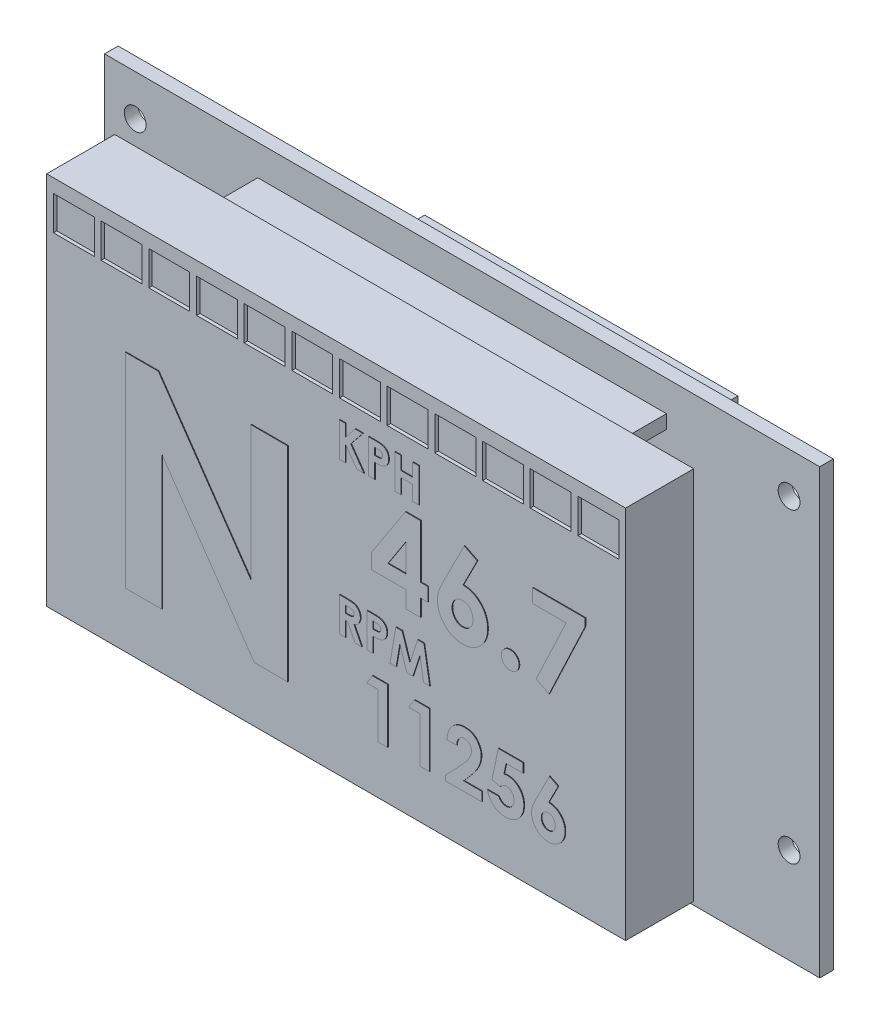
from build123d import *

# Parameters (mm, degrees)
SKETCH_1_W          = 105
SKETCH_1_H          = 67
EXTRUDE_1_DEPTH     = 2
SKETCH_2_R          = 1.6
CUT_EXTRUDE_1_DEPTH = 3
SKETCH_5_W          = 60
SKETCH_5_H          = 2
EXTRUDE_4_DEPTH     = 8.5
SKETCH_6_W          = 85
SKETCH_6_H          = 55
EXTRUDE_5_DEPTH     = 10
EXTRUDE_8_DEPTH     = 0.1
EXTRUDE_10_DEPTH    = 0.1
EXTRUDE_11_DEPTH    = 0.1
EXTRUDE_12_DEPTH    = 0.1
EXTRUDE_13_DEPTH    = 0.1
SKETCH_18_W         = 105
SKETCH_18_H         = 10
CUT_EXTRUDE_2_DEPTH = 10
SKETCH_19_W         = 45
SKETCH_19_H         = 2.5
EXTRUDE_14_DEPTH    = 8.5
SKETCH_22_W         = 46
SKETCH_22_H         = 19
EXTRUDE_15_DEPTH    = 7
SKETCH_28_W         = 105
SKETCH_28_H         = 8
EXTRUDE_16_DEPTH    = 2
SKETCH_29_W         = 6
SKETCH_29_H         = 5
CUT_EXTRUDE_3_DEPTH = 0.5


with BuildPart() as part:
    # ｽｹｯﾁ1 → ﾎﾞｽ - 押し出し1 (new body)
    with BuildSketch(Plane.XY):
        Rectangle(SKETCH_1_W, SKETCH_1_H)
    extrude(amount=EXTRUDE_1_DEPTH)

    # ｽｹｯﾁ2 → ｶｯﾄ - 押し出し1 (cut, through all)
    with BuildSketch(Plane.XY.offset(2)):
        with Locations((48, 17.5)):
            Circle(SKETCH_2_R)
        with Locations((48, -27.5)):
            Circle(SKETCH_2_R)
        with Locations((-48, -27.5)):
            Circle(SKETCH_2_R)
        with Locations((-48, 17.5)):
            Circle(SKETCH_2_R)
    extrude(amount=-CUT_EXTRUDE_1_DEPTH, mode=Mode.SUBTRACT)

    # ｽｹｯﾁ5 → ﾎﾞｽ - 押し出し4 (add)
    with BuildSketch(Plane.XY.offset(2)):
        with Locations((0, 18)):
            Rectangle(SKETCH_5_W, SKETCH_5_H)
        with Locations((0, -30)):
            Rectangle(SKETCH_5_W, SKETCH_5_H)
    extrude(amount=EXTRUDE_4_DEPTH)

    # ｽｹｯﾁ6 → ﾎﾞｽ - 押し出し5 (add)
    with BuildSketch(Plane.XY.offset(10.5)):
        with Locations((0, -5)):
            Rectangle(SKETCH_6_W, SKETCH_6_H)
    extrude(amount=EXTRUDE_5_DEPTH)

    # ｽｹｯﾁ10 → ﾎﾞｽ - 押し出し8 (add)
    with BuildSketch(Plane.XY.offset(20.5)):
        Polygon((-30.856693287, 5.696745875), (-26.006933671, 5.696745875), (-12.395154825, -14.044840664), (-12.395154825, 5.696745875), (-7.010539441, 5.696745875), (-7.010539441, -24.303254125), (-11.896356748, -24.303254125), (-25.472077902, -4.62176374), (-25.472077902, -24.303254125), (-30.856693287, -24.303254125), align=None)
    extrude(amount=EXTRUDE_8_DEPTH)

    # ｽｹｯﾁ12 → ﾎﾞｽ - 押し出し10 (add)
    with BuildSketch(Plane.XY.offset(20.5)):
        Polygon((0.576923077, 12.805093408), (1.474358974, 12.805093408), (1.474358974, 11.045277703), (2.892628205, 12.805093408), (4.025440705, 12.805093408), (2.243589744, 10.593554947), (4.198717949, 7.805093408), (3.117988782, 7.805093408), (1.474358974, 10.149845011), (1.474358974, 7.805093408), (0.576923077, 7.805093408), align=None)
        with BuildLine():
            Line((4.871794872, 12.805093408), (5.873397436, 12.805093408))
            add(Edge.make_bspline(
                [(5.873397436, 12.805093408), (5.938840848, 12.80480047), (6.065094908, 12.804235329), (6.24716365, 12.797382255), (6.415130978, 12.785101127), (6.568958304, 12.769923596), (6.708582377, 12.748645288), (6.834178047, 12.724251373), (6.94577138, 12.694532485), (7.044620756, 12.659256578), (7.133334878, 12.617667661), (7.21728705, 12.573372496), (7.294579944, 12.520507778), (7.369114766, 12.464771043), (7.436630232, 12.400837782), (7.50133836, 12.332962846), (7.560498585, 12.25845437), (7.614385033, 12.178214261), (7.663268345, 12.093725011), (7.705976076, 12.00483558), (7.740618196, 11.911405308), (7.769678627, 11.814038585), (7.793020249, 11.712739652), (7.808557175, 11.606885513), (7.819110637, 11.497215282), (7.820041834, 11.422573653), (7.820512821, 11.384820972)],
                knots=[0, 0, 0, 0, 0.000196324, 0.000378751, 0.00054645, 0.000701527, 0.000842329, 0.000970009, 0.001085176, 0.001188463, 0.001284371, 0.001378936, 0.001472831, 0.001564984, 0.001657831, 0.001751361, 0.001846154, 0.001942828, 0.002041098, 0.002138763, 0.00223829, 0.002339695, 0.002443447, 0.002549829, 0.002660459, 0.00277368, 0.00277368, 0.00277368, 0.00277368], degree=3))
            add(Edge.make_bspline(
                [(7.820512821, 11.384820972), (7.819831362, 11.34305608), (7.818492213, 11.260982936), (7.805364232, 11.140673775), (7.782937494, 11.025969882), (7.75362692, 10.91590394), (7.712755409, 10.812286777), (7.666061627, 10.712646055), (7.608613464, 10.619775395), (7.542969755, 10.532513096), (7.471279335, 10.450149675), (7.391840277, 10.37506322), (7.306166724, 10.306741869), (7.21475461, 10.244469609), (7.117260745, 10.188372057), (7.013755477, 10.137923918), (6.903532013, 10.094738682), (6.826775708, 10.072153153), (6.787860577, 10.060702383)],
                knots=[0, 0, 0, 0, 0.000125264, 0.00024616, 0.000362449, 0.000475684, 0.000587289, 0.000696151, 0.000805404, 0.000914178, 0.001023477, 0.001132583, 0.00124161, 0.0013519, 0.001464084, 0.001578762, 0.001697057, 0.00181871, 0.00181871, 0.00181871, 0.00181871], degree=3))
            add(Edge.make_bspline(
                [(6.787860577, 10.060702383), (6.762228833, 10.054325163), (6.706702221, 10.040510052), (6.61482093, 10.026484247), (6.508937389, 10.013588382), (6.388709207, 10.002505947), (6.25406707, 9.994972473), (6.105141347, 9.989089166), (5.941864548, 9.984811393), (5.828328318, 9.984659599), (5.769230769, 9.984580588)],
                knots=[0, 0, 0, 0, 7.9203e-05, 0.000171578, 0.000278544, 0.00039924, 0.000533694, 0.000683053, 0.000846364, 0.00102365, 0.00102365, 0.00102365, 0.00102365], degree=3))
            Line((5.769230769, 9.984580588), (5.769230769, 7.805093408))
            Line((5.769230769, 7.805093408), (4.871794872, 7.805093408))
            Line((4.871794872, 7.805093408), (4.871794872, 12.805093408))
        make_face()
        with BuildLine():
            Line((5.769230769, 10.882016485), (6.086738782, 10.882016485))
            add(Edge.make_bspline(
                [(6.086738782, 10.882016485), (6.144514378, 10.882382827), (6.250822332, 10.883056902), (6.396001457, 10.892804418), (6.512670194, 10.907690843), (6.604840663, 10.929041419), (6.677617979, 10.961443746), (6.740383857, 10.998927136), (6.794219753, 11.046323854), (6.840833715, 11.100482714), (6.878100173, 11.162713958), (6.90394252, 11.232004273), (6.920729201, 11.306897793), (6.922279607, 11.359018726), (6.923076923, 11.385822575)],
                knots=[0, 0, 0, 0, 0.000173303, 0.000318881, 0.000436167, 0.000526049, 0.000601409, 0.000674244, 0.000744535, 0.000815585, 0.000887902, 0.00096082, 0.001036651, 0.001116936, 0.001116936, 0.001116936, 0.001116936], degree=3))
            add(Edge.make_bspline(
                [(6.923076923, 11.385822575), (6.922287809, 11.409240749), (6.920756737, 11.454677636), (6.909509069, 11.520254335), (6.89158352, 11.581385346), (6.86561009, 11.637432237), (6.832032594, 11.688299775), (6.791094833, 11.733967922), (6.743322116, 11.775414699), (6.706438786, 11.797353112), (6.687700321, 11.808498857)],
                knots=[0, 0, 0, 0, 7.0227e-05, 0.000136256, 0.000198999, 0.000260839, 0.000320843, 0.000381148, 0.000444376, 0.000509672, 0.000509672, 0.000509672, 0.000509672], degree=3))
            add(Edge.make_bspline(
                [(6.687700321, 11.808498857), (6.671827758, 11.816526067), (6.638222292, 11.833521315), (6.580988924, 11.853279533), (6.514942491, 11.869947767), (6.439637106, 11.883782241), (6.355373184, 11.894519229), (6.262165757, 11.902730338), (6.159877664, 11.906032345), (6.088742415, 11.907100847), (6.051682692, 11.907657511)],
                knots=[0, 0, 0, 0, 5.3311e-05, 0.000112871, 0.000181134, 0.000257552, 0.000342405, 0.000435898, 0.00053814, 0.000649336, 0.000649336, 0.000649336, 0.000649336], degree=3))
            Line((6.051682692, 11.907657511), (5.769230769, 11.907657511))
            Line((5.769230769, 11.907657511), (5.769230769, 10.882016485))
        make_face(mode=Mode.SUBTRACT)
        Polygon((8.717948718, 12.805093408), (9.615384615, 12.805093408), (9.615384615, 10.882016485), (11.346153846, 10.882016485), (11.346153846, 12.805093408), (12.243589744, 12.805093408), (12.243589744, 7.805093408), (11.346153846, 7.805093408), (11.346153846, 9.984580588), (9.615384615, 9.984580588), (9.615384615, 7.805093408), (8.717948718, 7.805093408), align=None)
    extrude(amount=EXTRUDE_10_DEPTH)

    # ｽｹｯﾁ13 → ﾎﾞｽ - 押し出し11 (add)
    with BuildSketch(Plane.XY.offset(20.5)):
        Polygon((10.259436868, 5.95275545), (12.504629176, 5.95275545), (12.504629176, -1.893398396), (13.581552253, -1.893398396), (13.581552253, -3.893398396), (12.504629176, -3.893398396), (12.504629176, -6.354936858), (10.350783022, -6.354936858), (10.350783022, -3.893398396), (5.273859945, -3.893398396), (5.273859945, -1.713109934), align=None)
        Polygon((10.350783022, -1.893398396), (10.350783022, 2.190736219), (7.694533022, -1.893398396), align=None, mode=Mode.SUBTRACT)
        with BuildLine():
            Line((18.918090715, 5.95275545), (20.824340715, 4.986409296))
            Line((20.824340715, 4.986409296), (18.732994561, 0.875832373))
            add(Edge.make_bspline(
                [(18.732994561, 0.875832373), (18.856549329, 0.872633478), (19.099910708, 0.866332729), (19.457967596, 0.815409024), (19.800276646, 0.727374147), (20.130289346, 0.610684157), (20.443971602, 0.453968341), (20.746375442, 0.267546702), (21.029677525, 0.040185462), (21.300373727, -0.21171873), (21.546516393, -0.490792371), (21.760334814, -0.790665864), (21.946673794, -1.10404325), (22.091526217, -1.43793554), (22.208369006, -1.786808092), (22.29267622, -2.152055499), (22.340775844, -2.534735435), (22.347407179, -2.794707251), (22.350783022, -2.927052242)],
                knots=[0, 0, 0, 0, 0.000370575, 0.000729907, 0.001082052, 0.001429547, 0.001777865, 0.002132047, 0.002493208, 0.002865649, 0.003240356, 0.003607264, 0.003969248, 0.004331942, 0.004696821, 0.005071767, 0.005454605, 0.005851596, 0.005851596, 0.005851596, 0.005851596], degree=3))
            add(Edge.make_bspline(
                [(22.350783022, -2.927052242), (22.347619578, -3.054624786), (22.341366805, -3.306780999), (22.28967936, -3.677134346), (22.206149734, -4.032466724), (22.086769124, -4.372068491), (21.935026714, -4.697599628), (21.749456025, -5.008869112), (21.528518109, -5.303550928), (21.27792139, -5.580079278), (21.003975945, -5.832136913), (20.715222525, -6.056180409), (20.40921427, -6.241248837), (20.091735094, -6.397543463), (19.756940012, -6.514173112), (19.409839247, -6.602208293), (19.047800634, -6.653008414), (18.8020581, -6.659396587), (18.677706099, -6.662629165)],
                knots=[0, 0, 0, 0, 0.000382582, 0.0007562, 0.001119443, 0.001476, 0.001834116, 0.002195254, 0.00256112, 0.002937236, 0.003313198, 0.003676679, 0.004031644, 0.004384281, 0.004736303, 0.00509311, 0.005457203, 0.005830179, 0.005830179, 0.005830179, 0.005830179], degree=3))
            add(Edge.make_bspline(
                [(18.677706099, -6.662629165), (18.547671696, -6.659976359), (18.291976635, -6.654759976), (17.917830769, -6.596350228), (17.558992683, -6.508422495), (17.217479104, -6.382876631), (16.891166261, -6.223017787), (16.583895901, -6.025208546), (16.293079695, -5.791630215), (16.02181817, -5.527537936), (15.777431751, -5.238260978), (15.55945949, -4.937916181), (15.375054677, -4.626032237), (15.225783279, -4.30294261), (15.109318272, -3.969676838), (15.028282382, -3.625602412), (14.97548002, -3.271631987), (14.969290148, -3.031407626), (14.966167638, -2.910225319)],
                knots=[0, 0, 0, 0, 0.000389786, 0.000766462, 0.001133181, 0.001496695, 0.001855762, 0.002221178, 0.002590589, 0.002973073, 0.00335505, 0.003725312, 0.004085224, 0.004440147, 0.004791372, 0.005142367, 0.00549932, 0.00586269, 0.00586269, 0.00586269, 0.00586269], degree=3))
            add(Edge.make_bspline(
                [(14.966167638, -2.910225319), (14.967817511, -2.816383799), (14.971126441, -2.628178397), (15.004379209, -2.346351036), (15.054935096, -2.063783904), (15.113535989, -1.82534481), (15.173877268, -1.623719604), (15.234611228, -1.45308964), (15.309877591, -1.263727689), (15.395918192, -1.055150199), (15.495438697, -0.827608087), (15.607919226, -0.581721574), (15.733639807, -0.315628621), (15.823295897, -0.132863966), (15.870013792, -0.037629165)],
                knots=[0, 0, 0, 0, 0.000281414, 0.000564395, 0.00085014, 0.001142234, 0.001300414, 0.001481358, 0.001685359, 0.001911691, 0.002158212, 0.002430367, 0.002722847, 0.003041073, 0.003041073, 0.003041073, 0.003041073], degree=3))
            Line((15.870013792, -0.037629165), (18.918090715, 5.95275545))
        make_face()
        with BuildLine():
            add(Edge.make_bspline(
                [(18.629629176, -1.124167627), (18.526281082, -1.128907985), (18.324042429, -1.138184245), (18.036489308, -1.235329753), (17.774306104, -1.387726876), (17.54704246, -1.599969344), (17.356957333, -1.853607426), (17.217276113, -2.142915539), (17.133250095, -2.464032943), (17.12452033, -2.688552879), (17.120013792, -2.804456088)],
                knots=[0, 0, 0, 0, 0.000309042, 0.000604754, 0.000899948, 0.001213002, 0.001530792, 0.001845806, 0.002171143, 0.002518305, 0.002518305, 0.002518305, 0.002518305], degree=3))
            add(Edge.make_bspline(
                [(17.120013792, -2.804456088), (17.125349675, -2.920397893), (17.135728324, -3.145912454), (17.222913829, -3.47008747), (17.365663554, -3.765965434), (17.56586094, -4.022964772), (17.800889794, -4.23629412), (18.061508917, -4.394061374), (18.343371087, -4.490982975), (18.538342034, -4.502808696), (18.636840715, -4.508783011)],
                knots=[0, 0, 0, 0, 0.000347354, 0.000675626, 0.000999227, 0.001326653, 0.001646663, 0.001946374, 0.002235236, 0.002530165, 0.002530165, 0.002530165, 0.002530165], degree=3))
            add(Edge.make_bspline(
                [(18.636840715, -4.508783011), (18.740866454, -4.502702289), (18.944878998, -4.490776937), (19.239180471, -4.39793362), (19.508026633, -4.242809485), (19.745738644, -4.030163129), (19.949928744, -3.776096499), (20.091207669, -3.478480589), (20.182423799, -3.151965793), (20.191990714, -2.922889805), (20.196936868, -2.804456088)],
                knots=[0, 0, 0, 0, 0.000311667, 0.000611233, 0.000915953, 0.001236161, 0.001563164, 0.001886765, 0.002217981, 0.002572522, 0.002572522, 0.002572522, 0.002572522], degree=3))
            add(Edge.make_bspline(
                [(20.196936868, -2.804456088), (20.191302295, -2.688620554), (20.180390284, -2.464291516), (20.098428156, -2.14166975), (19.952090312, -1.853476738), (19.757704355, -1.598922365), (19.522619503, -1.386774538), (19.249943192, -1.234127901), (18.949254166, -1.138356356), (18.737724224, -1.128966161), (18.629629176, -1.124167627)],
                knots=[0, 0, 0, 0, 0.000347354, 0.000672691, 0.000989826, 0.001310512, 0.001628919, 0.001932452, 0.002241914, 0.002565318, 0.002565318, 0.002565318, 0.002565318], degree=3))
        make_face(mode=Mode.SUBTRACT)
        with BuildLine():
            add(Edge.make_bspline(
                [(25.65847533, -3.893398396), (25.745423546, -3.898165558), (25.916609565, -3.907551276), (26.163950022, -3.977595909), (26.38717621, -4.103441071), (26.586770247, -4.267584273), (26.75554194, -4.465070461), (26.877526302, -4.690279312), (26.953489024, -4.936666733), (26.961875362, -5.108391325), (26.966167638, -5.196283011)],
                knots=[0, 0, 0, 0, 0.000260726, 0.000513324, 0.000762919, 0.001024232, 0.001285235, 0.001536939, 0.001787908, 0.002051028, 0.002051028, 0.002051028, 0.002051028], degree=3))
            add(Edge.make_bspline(
                [(26.966167638, -5.196283011), (26.96190348, -5.284188814), (26.953572081, -5.455940985), (26.877000647, -5.70280851), (26.755724223, -5.929868372), (26.586756706, -6.129470754), (26.388002798, -6.296707389), (26.163436786, -6.421392075), (25.917080744, -6.495410161), (25.745506478, -6.504282508), (25.65847533, -6.508783011)],
                knots=[0, 0, 0, 0, 0.00026312, 0.000514089, 0.000767908, 0.001030753, 0.001293598, 0.001543193, 0.001796465, 0.002057191, 0.002057191, 0.002057191, 0.002057191], degree=3))
            add(Edge.make_bspline(
                [(25.65847533, -6.508783011), (25.57142356, -6.504319105), (25.39980864, -6.495518905), (25.153069654, -6.420768175), (24.926845722, -6.297539832), (24.728041876, -6.129267897), (24.558319487, -5.930575181), (24.440491064, -5.702092095), (24.363206389, -5.456034057), (24.354988886, -5.284220323), (24.350783022, -5.196283011)],
                knots=[0, 0, 0, 0, 0.000260726, 0.000513998, 0.000765703, 0.001028548, 0.001291393, 0.001544083, 0.001795051, 0.002058171, 0.002058171, 0.002058171, 0.002058171], degree=3))
            add(Edge.make_bspline(
                [(24.350783022, -5.196283011), (24.355016634, -5.108359267), (24.363288351, -4.936572041), (24.439966907, -4.691003979), (24.558508329, -4.464359811), (24.728027722, -4.267787552), (24.927676568, -4.102615126), (25.152553538, -3.97821126), (25.400279581, -3.907441729), (25.571506395, -3.898128659), (25.65847533, -3.893398396)],
                knots=[0, 0, 0, 0, 0.00026312, 0.000514089, 0.000764654, 0.001025657, 0.00128697, 0.001538674, 0.001791272, 0.002051998, 0.002051998, 0.002051998, 0.002051998], degree=3))
        make_face()
        Polygon((28.966167638, 5.645063142), (36.65847533, 5.645063142), (36.65847533, 4.527274681), (31.365206099, -6.662629165), (29.456552253, -5.701090704), (33.879629176, 3.645063142), (28.966167638, 3.645063142), align=None)
    extrude(amount=EXTRUDE_11_DEPTH)

    # ｽｹｯﾁ14 → ﾎﾞｽ - 押し出し12 (add)
    with BuildSketch(Plane.XY.offset(20.5)):
        with BuildLine():
            Line((0.576923077, -9.415261778), (1.622596154, -9.415261778))
            add(Edge.make_bspline(
                [(1.622596154, -9.415261778), (1.691714826, -9.41550711), (1.824649502, -9.415978951), (2.016334044, -9.423423365), (2.192422657, -9.433782878), (2.353176056, -9.44959177), (2.498525468, -9.470552449), (2.628616566, -9.495261622), (2.74344555, -9.523423021), (2.843980841, -9.558514347), (2.934708971, -9.598096831), (3.019280201, -9.64357783), (3.099560299, -9.6944509), (3.175012679, -9.752054648), (3.246293041, -9.815352798), (3.313535858, -9.884409065), (3.375790927, -9.959809018), (3.432672764, -10.041076225), (3.484515979, -10.126567463), (3.530334507, -10.216400113), (3.567594211, -10.310636646), (3.600517153, -10.407915142), (3.624230482, -10.509626215), (3.640722755, -10.614779691), (3.652797752, -10.723745721), (3.653492007, -10.797772404), (3.653846154, -10.835534214)],
                knots=[0, 0, 0, 0, 0.000207341, 0.000398776, 0.000575402, 0.000736458, 0.000883205, 0.001015799, 0.001133619, 0.001237515, 0.001334841, 0.001430288, 0.001525314, 0.001619667, 0.00171474, 0.001811071, 0.001908535, 0.00200774, 0.002108399, 0.002208289, 0.002309842, 0.002412147, 0.002516126, 0.002622664, 0.002731397, 0.002844618, 0.002844618, 0.002844618, 0.002844618], degree=3))
            add(Edge.make_bspline(
                [(3.653846154, -10.835534214), (3.652926208, -10.874948869), (3.651122362, -10.952233824), (3.641405864, -11.06575912), (3.623647158, -11.174372182), (3.596749014, -11.277755005), (3.565833092, -11.377194308), (3.524722845, -11.470855375), (3.478325869, -11.560100369), (3.423221536, -11.643666887), (3.362747222, -11.723411108), (3.292416868, -11.796277734), (3.216786799, -11.866183072), (3.131605574, -11.928748488), (3.040628061, -11.988204428), (2.942046631, -12.042087345), (2.836504663, -12.091751729), (2.762303432, -12.11944802), (2.724358974, -12.133611137)],
                knots=[0, 0, 0, 0, 0.000118257, 0.00023188, 0.000341546, 0.000447947, 0.000552157, 0.000653556, 0.000754365, 0.000853544, 0.000953514, 0.001054124, 0.001156939, 0.001262107, 0.001370733, 0.001482805, 0.001598862, 0.00172032, 0.00172032, 0.00172032, 0.00172032], degree=3))
            Line((2.724358974, -12.133611137), (3.878205128, -14.415261778))
            Line((3.878205128, -14.415261778), (2.880608974, -14.415261778))
            Line((2.880608974, -14.415261778), (1.778846154, -12.235774599))
            Line((1.778846154, -12.235774599), (1.474358974, -12.235774599))
            Line((1.474358974, -12.235774599), (1.474358974, -14.415261778))
            Line((1.474358974, -14.415261778), (0.576923077, -14.415261778))
            Line((0.576923077, -14.415261778), (0.576923077, -9.415261778))
        make_face()
        with BuildLine():
            Line((1.474358974, -11.338338701), (1.823918269, -11.338338701))
            add(Edge.make_bspline(
                [(1.823918269, -11.338338701), (1.866654799, -11.337857374), (1.94848607, -11.336935735), (2.066170185, -11.332660792), (2.173055429, -11.322360293), (2.269600801, -11.309345997), (2.356292109, -11.294319112), (2.432356098, -11.272784675), (2.498964797, -11.24970998), (2.555328891, -11.22103412), (2.603485078, -11.188423448), (2.645064864, -11.151376913), (2.679457308, -11.108500267), (2.707764044, -11.060958711), (2.729783607, -11.008331751), (2.745856201, -10.951197114), (2.754838404, -10.888903961), (2.755871837, -10.845913204), (2.756410256, -10.823514983)],
                knots=[0, 0, 0, 0, 0.000128221, 0.000245515, 0.000353154, 0.000450185, 0.000537801, 0.000616775, 0.000687116, 0.000748932, 0.000805883, 0.000861198, 0.000915322, 0.000970118, 0.001026671, 0.001085968, 0.001147728, 0.001214902, 0.001214902, 0.001214902, 0.001214902], degree=3))
            add(Edge.make_bspline(
                [(2.756410256, -10.823514983), (2.755392325, -10.797016253), (2.753392787, -10.744964408), (2.733551162, -10.670028003), (2.701967581, -10.600669233), (2.658675143, -10.537201478), (2.604153944, -10.481561263), (2.541586567, -10.43251397), (2.469622657, -10.393731041), (2.402989491, -10.368150234), (2.342368886, -10.352844973), (2.287660702, -10.341439628), (2.224308295, -10.333356333), (2.152263839, -10.324782559), (2.071710976, -10.319222901), (1.982210645, -10.315165459), (1.884019891, -10.31350536), (1.81557161, -10.312974655), (1.779847756, -10.312697675)],
                knots=[0, 0, 0, 0, 7.9354e-05, 0.000155877, 0.00023073, 0.000307128, 0.000385047, 0.000463582, 0.000544718, 0.000629358, 0.000676973, 0.000732171, 0.000796904, 0.000868468, 0.00094982, 0.001039053, 0.00113723, 0.001244406, 0.001244406, 0.001244406, 0.001244406], degree=3))
            Line((1.779847756, -10.312697675), (1.474358974, -10.312697675))
            Line((1.474358974, -10.312697675), (1.474358974, -11.338338701))
        make_face(mode=Mode.SUBTRACT)
        with BuildLine():
            Line((4.615384615, -9.415261778), (5.616987179, -9.415261778))
            add(Edge.make_bspline(
                [(5.616987179, -9.415261778), (5.682430592, -9.415554717), (5.808684652, -9.416119857), (5.990753393, -9.422972931), (6.158720722, -9.435254059), (6.312548048, -9.45043159), (6.45217212, -9.471709899), (6.577767791, -9.496103813), (6.689361124, -9.525822701), (6.7882105, -9.561098608), (6.876924621, -9.602687525), (6.960876794, -9.646982691), (7.038169688, -9.699847408), (7.11270451, -9.755584143), (7.180219976, -9.819517404), (7.244928104, -9.88739234), (7.304088329, -9.961900816), (7.357974777, -10.042140926), (7.406858088, -10.126630175), (7.44956582, -10.215519607), (7.48420794, -10.308949878), (7.513268371, -10.406316602), (7.536609992, -10.507615534), (7.552146918, -10.613469673), (7.56270038, -10.723139904), (7.563631578, -10.797781533), (7.564102564, -10.835534214)],
                knots=[0, 0, 0, 0, 0.000196324, 0.000378751, 0.00054645, 0.000701527, 0.000842329, 0.000970009, 0.001085176, 0.001188463, 0.001284371, 0.001378936, 0.001472831, 0.001564984, 0.001657831, 0.001751361, 0.001846154, 0.001942828, 0.002041098, 0.002138763, 0.00223829, 0.002339695, 0.002443447, 0.002549829, 0.002660459, 0.00277368, 0.00277368, 0.00277368, 0.00277368], degree=3))
            add(Edge.make_bspline(
                [(7.564102564, -10.835534214), (7.563421106, -10.877299106), (7.562081956, -10.95937225), (7.548953976, -11.079681411), (7.526527237, -11.194385304), (7.497216663, -11.304451246), (7.456345153, -11.408068409), (7.409651371, -11.507709131), (7.352203208, -11.600579791), (7.286559498, -11.68784209), (7.214869078, -11.770205511), (7.13543002, -11.845291966), (7.049756468, -11.913613317), (6.958344353, -11.975885577), (6.860850489, -12.031983129), (6.75734522, -12.082431268), (6.647121756, -12.125616504), (6.570365452, -12.148202033), (6.531450321, -12.159652804)],
                knots=[0, 0, 0, 0, 0.000125264, 0.00024616, 0.000362449, 0.000475684, 0.000587289, 0.000696151, 0.000805404, 0.000914178, 0.001023477, 0.001132583, 0.00124161, 0.0013519, 0.001464084, 0.001578762, 0.001697057, 0.00181871, 0.00181871, 0.00181871, 0.00181871], degree=3))
            add(Edge.make_bspline(
                [(6.531450321, -12.159652804), (6.505818576, -12.166030023), (6.450291965, -12.179845134), (6.358410673, -12.193870939), (6.252527132, -12.206766804), (6.132298951, -12.217849239), (5.997656814, -12.225382713), (5.848731091, -12.231266021), (5.685454291, -12.235543793), (5.571918061, -12.235695587), (5.512820513, -12.235774599)],
                knots=[0, 0, 0, 0, 7.9203e-05, 0.000171578, 0.000278544, 0.00039924, 0.000533694, 0.000683053, 0.000846364, 0.00102365, 0.00102365, 0.00102365, 0.00102365], degree=3))
            Line((5.512820513, -12.235774599), (5.512820513, -14.415261778))
            Line((5.512820513, -14.415261778), (4.615384615, -14.415261778))
            Line((4.615384615, -14.415261778), (4.615384615, -9.415261778))
        make_face()
        with BuildLine():
            Line((5.512820513, -11.338338701), (5.830328526, -11.338338701))
            add(Edge.make_bspline(
                [(5.830328526, -11.338338701), (5.888104121, -11.337972359), (5.994412076, -11.337298284), (6.1395912, -11.327550769), (6.256259938, -11.312664343), (6.348430407, -11.291313767), (6.421207722, -11.258911441), (6.4839736, -11.22142805), (6.537809496, -11.174031332), (6.584423459, -11.119872472), (6.621689916, -11.057641228), (6.647532264, -10.988350913), (6.664318945, -10.913457393), (6.665869351, -10.86133646), (6.666666667, -10.834532611)],
                knots=[0, 0, 0, 0, 0.000173303, 0.000318881, 0.000436167, 0.000526049, 0.000601409, 0.000674244, 0.000744535, 0.000815585, 0.000887902, 0.00096082, 0.001036651, 0.001116936, 0.001116936, 0.001116936, 0.001116936], degree=3))
            add(Edge.make_bspline(
                [(6.666666667, -10.834532611), (6.665877552, -10.811114438), (6.664346481, -10.76567755), (6.653098812, -10.700100852), (6.635173264, -10.63896984), (6.609199833, -10.58292295), (6.575622338, -10.532055411), (6.534684576, -10.486387264), (6.48691186, -10.444940487), (6.45002853, -10.423002074), (6.431290064, -10.411856329)],
                knots=[0, 0, 0, 0, 7.0227e-05, 0.000136256, 0.000198999, 0.000260839, 0.000320843, 0.000381148, 0.000444376, 0.000509672, 0.000509672, 0.000509672, 0.000509672], degree=3))
            add(Edge.make_bspline(
                [(6.431290064, -10.411856329), (6.415417502, -10.403829119), (6.381812035, -10.386833871), (6.324578667, -10.367075653), (6.258532235, -10.350407419), (6.18322685, -10.336572946), (6.098962927, -10.325835958), (6.005755501, -10.317624848), (5.903467407, -10.314322841), (5.832332159, -10.313254339), (5.795272436, -10.312697675)],
                knots=[0, 0, 0, 0, 5.3311e-05, 0.000112871, 0.000181134, 0.000257552, 0.000342405, 0.000435898, 0.00053814, 0.000649336, 0.000649336, 0.000649336, 0.000649336], degree=3))
            Line((5.795272436, -10.312697675), (5.512820513, -10.312697675))
            Line((5.512820513, -10.312697675), (5.512820513, -11.338338701))
        make_face(mode=Mode.SUBTRACT)
        Polygon((8.857171474, -9.415261778), (9.788661859, -9.415261778), (10.929487179, -12.902841906), (12.078325321, -9.415261778), (13.000801282, -9.415261778), (13.846153846, -14.415261778), (12.937700321, -14.415261778), (12.403846154, -11.257208893), (11.364182692, -14.415261778), (10.488782051, -14.415261778), (9.455128205, -11.257208893), (8.922275641, -14.415261778), (8.012820513, -14.415261778), align=None)
    extrude(amount=EXTRUDE_12_DEPTH)

    # ｽｹｯﾁ15 → ﾎﾞｽ - 押し出し13 (add)
    with BuildSketch(Plane.XY.offset(20.5)):
        Polygon((5.439536639, -17.307592752), (7.659087921, -17.307592752), (7.659087921, -25.307592752), (6.223190485, -25.307592752), (6.223190485, -18.640926085), (4.582164844, -18.640926085), align=None)
        Polygon((11.593382793, -17.307592752), (13.812934075, -17.307592752), (13.812934075, -25.307592752), (12.377036639, -25.307592752), (12.377036639, -18.640926085), (10.736010998, -18.640926085), align=None)
        with BuildLine():
            Line((17.812934075, -19.974259418), (16.377036639, -19.974259418))
            add(Edge.make_bspline(
                [(16.377036639, -19.974259418), (16.38323806, -19.865641374), (16.395355264, -19.653408236), (16.443554438, -19.345132808), (16.508139678, -19.053846428), (16.594337254, -18.780568047), (16.702650149, -18.525396966), (16.830291192, -18.287463293), (16.980521323, -18.068019754), (17.150143149, -17.868124629), (17.33627696, -17.688796868), (17.535058433, -17.52979361), (17.749528201, -17.398588122), (17.975767724, -17.290618153), (18.213738479, -17.204355165), (18.465692043, -17.146681377), (18.729446865, -17.107624122), (18.910008399, -17.104206456), (19.002036639, -17.102464547)],
                knots=[0, 0, 0, 0, 0.000326207, 0.00063739, 0.000934802, 0.001220652, 0.001495683, 0.001765295, 0.002029329, 0.002291978, 0.002550384, 0.00280367, 0.003054066, 0.003302794, 0.003554723, 0.003811658, 0.004077051, 0.00435292, 0.00435292, 0.00435292, 0.00435292], degree=3))
            add(Edge.make_bspline(
                [(19.002036639, -17.102464547), (19.114999998, -17.105989301), (19.335530947, -17.112870448), (19.655979909, -17.171568916), (19.955244202, -17.269751173), (20.23310629, -17.40693768), (20.487200684, -17.581218757), (20.717485248, -17.789020417), (20.91699581, -18.03470245), (21.086997325, -18.308042426), (21.228248266, -18.597470991), (21.327231042, -18.89675213), (21.392291355, -19.197944134), (21.399230441, -19.400751585), (21.402677664, -19.501503008)],
                knots=[0, 0, 0, 0, 0.000338687, 0.000661197, 0.000973372, 0.001280835, 0.001587541, 0.001894987, 0.002208111, 0.002533585, 0.002859001, 0.003171681, 0.003477486, 0.003779381, 0.003779381, 0.003779381, 0.003779381], degree=3))
            add(Edge.make_bspline(
                [(21.402677664, -19.501503008), (21.401335498, -19.56244459), (21.398634047, -19.68510494), (21.379850502, -19.870720156), (21.351671474, -20.059790954), (21.309184366, -20.252155224), (21.25619946, -20.447866888), (21.19192111, -20.647511646), (21.114858316, -20.849957583), (21.026297102, -21.057483195), (20.920643348, -21.270762235), (20.797624238, -21.49299184), (20.653974566, -21.723974874), (20.491429438, -21.965015543), (20.309199411, -22.215733689), (20.1063949, -22.47537407), (19.885351735, -22.744851575), (19.728471182, -22.924982165), (19.647869972, -23.017528649)],
                knots=[0, 0, 0, 0, 0.000182805, 0.000367941, 0.000559231, 0.000756001, 0.00095854, 0.001167341, 0.001384918, 0.001608181, 0.001843976, 0.002098627, 0.002369916, 0.002659714, 0.002970649, 0.003299545, 0.003647962, 0.00401612, 0.00401612, 0.00401612, 0.00401612], degree=3))
            Line((19.647869972, -23.017528649), (18.812934075, -23.974259418))
            Line((18.812934075, -23.974259418), (21.505241767, -23.974259418))
            Line((21.505241767, -23.974259418), (21.505241767, -25.307592752))
            Line((21.505241767, -25.307592752), (16.171908434, -25.307592752))
            Line((16.171908434, -25.307592752), (16.171908434, -24.580028649))
            Line((16.171908434, -24.580028649), (18.540498177, -22.059195316))
            add(Edge.make_bspline(
                [(18.540498177, -22.059195316), (18.609074937, -21.985661825), (18.741887784, -21.843249259), (18.930866778, -21.634101256), (19.101876075, -21.435624793), (19.251369656, -21.245706496), (19.387192754, -21.070506543), (19.503289026, -20.904744188), (19.600720663, -20.749917982), (19.706496524, -20.563224618), (19.80694882, -20.340559559), (19.899119882, -20.084040282), (19.955304523, -19.83886693), (19.96305978, -19.679106704), (19.966780229, -19.602464547)],
                knots=[0, 0, 0, 0, 0.00030164, 0.000584187, 0.000845616, 0.001087386, 0.001309189, 0.001510583, 0.001694215, 0.00185781, 0.002153973, 0.002425634, 0.002674899, 0.002904742, 0.002904742, 0.002904742, 0.002904742], degree=3))
            add(Edge.make_bspline(
                [(19.966780229, -19.602464547), (19.963998539, -19.528319172), (19.95860857, -19.384650621), (19.89937718, -19.180282872), (19.807613856, -18.995248737), (19.678306372, -18.835077246), (19.521674511, -18.70345371), (19.340671682, -18.605555823), (19.136773591, -18.54906919), (18.993837144, -18.541999082), (18.92030587, -18.538361982)],
                knots=[0, 0, 0, 0, 0.000221855, 0.00042988, 0.000632704, 0.000837933, 0.00104271, 0.001242748, 0.001450773, 0.001671165, 0.001671165, 0.001671165, 0.001671165], degree=3))
            add(Edge.make_bspline(
                [(18.92030587, -18.538361982), (18.882318677, -18.539705571), (18.807534787, -18.54235064), (18.697608314, -18.559958148), (18.593005377, -18.590989544), (18.492561688, -18.632567247), (18.397349207, -18.687678791), (18.307608092, -18.755612549), (18.222392805, -18.834642171), (18.142094179, -18.92452054), (18.069011947, -19.024824827), (18.004100575, -19.134638956), (17.950429677, -19.253894764), (17.903175868, -19.38101789), (17.866731469, -19.517373741), (17.840195425, -19.662146243), (17.820021843, -19.815099869), (17.815339644, -19.920241104), (17.812934075, -19.974259418)],
                knots=[0, 0, 0, 0, 0.000113962, 0.000224353, 0.000332879, 0.000440621, 0.000549748, 0.000661928, 0.000777602, 0.000897911, 0.001022922, 0.001149352, 0.00127986, 0.001414723, 0.00155584, 0.001702621, 0.001856074, 0.002018219, 0.002018219, 0.002018219, 0.002018219], degree=3))
        make_face()
        with BuildLine():
            Line((23.913895613, -17.307592752), (27.556523818, -17.307592752))
            Line((27.556523818, -17.307592752), (27.556523818, -18.640926085))
            Line((27.556523818, -18.640926085), (25.051716126, -18.640926085))
            Line((25.051716126, -18.640926085), (24.739216126, -20.153746598))
            add(Edge.make_bspline(
                [(24.739216126, -20.153746598), (24.781798724, -20.141886807), (24.865780357, -20.118496862), (24.992298792, -20.095039706), (25.114912786, -20.079835524), (25.195371341, -20.077807488), (25.234408434, -20.076823521)],
                knots=[0, 0, 0, 0, 0.000132549, 0.000261413, 0.000385651, 0.000502737, 0.000502737, 0.000502737, 0.000502737], degree=3))
            add(Edge.make_bspline(
                [(25.234408434, -20.076823521), (25.319474349, -20.078772757), (25.487158007, -20.082615131), (25.73245792, -20.119091792), (25.967347077, -20.176541427), (26.191106693, -20.25847646), (26.403518183, -20.365117022), (26.604839033, -20.494122208), (26.795316329, -20.645718599), (26.971566394, -20.820001106), (27.133512315, -21.011367245), (27.274315058, -21.218349973), (27.394569386, -21.437997918), (27.490215522, -21.671676406), (27.565707606, -21.91791778), (27.620259872, -22.176879838), (27.652519352, -22.44886949), (27.656869345, -22.634428583), (27.659087921, -22.729067111)],
                knots=[0, 0, 0, 0, 0.000255055, 0.000502769, 0.000742195, 0.000979472, 0.001215979, 0.001453813, 0.001695582, 0.001944893, 0.002196251, 0.002446502, 0.002694626, 0.002946106, 0.003202606, 0.003466309, 0.003739033, 0.004022908, 0.004022908, 0.004022908, 0.004022908], degree=3))
            add(Edge.make_bspline(
                [(27.659087921, -22.729067111), (27.656376785, -22.824780005), (27.651026923, -23.013649524), (27.61612397, -23.291354525), (27.554519631, -23.557333223), (27.469899909, -23.812297637), (27.358418841, -24.054373839), (27.224347599, -24.286069559), (27.0654194, -24.505664992), (26.883193874, -24.710909019), (26.685090825, -24.898506001), (26.47415784, -25.063535425), (26.25187679, -25.202406348), (26.018242309, -25.314637532), (25.774594833, -25.403432846), (25.520860413, -25.468071597), (25.255805932, -25.505138329), (25.075868377, -25.51016564), (24.984408434, -25.512720957)],
                knots=[0, 0, 0, 0, 0.000287145, 0.000566622, 0.000837967, 0.001105038, 0.001371092, 0.001636063, 0.001906939, 0.002182827, 0.002458305, 0.002724374, 0.002984957, 0.00324299, 0.00350053, 0.003761723, 0.004027116, 0.004301454, 0.004301454, 0.004301454, 0.004301454], degree=3))
            add(Edge.make_bspline(
                [(24.984408434, -25.512720957), (24.902618529, -25.510630548), (24.741311719, -25.506507825), (24.50371387, -25.481167397), (24.274643159, -25.436365282), (24.055315702, -25.371525021), (23.843423806, -25.291721462), (23.641417002, -25.19191203), (23.448185228, -25.073997231), (23.264277189, -24.940129013), (23.092681131, -24.789331658), (22.936066431, -24.624257971), (22.793484925, -24.446988626), (22.667987634, -24.255336657), (22.559967953, -24.049585219), (22.464173897, -23.832159142), (22.385765502, -23.600787801), (22.3459755, -23.440388334), (22.325754588, -23.358874803)],
                knots=[0, 0, 0, 0, 0.000245381, 0.000483942, 0.000715888, 0.000944606, 0.001169314, 0.001394359, 0.001619455, 0.001847678, 0.002075924, 0.002303764, 0.002529516, 0.002757536, 0.002989814, 0.003225919, 0.003469683, 0.003721566, 0.003721566, 0.003721566, 0.003721566], degree=3))
            Line((22.325754588, -23.358874803), (23.966780229, -23.358874803))
            add(Edge.make_bspline(
                [(23.966780229, -23.358874803), (23.996778217, -23.41536036), (24.055075884, -23.525133595), (24.165970935, -23.670874058), (24.290110904, -23.795155264), (24.426375981, -23.899191467), (24.57564908, -23.977133619), (24.731847602, -24.036241342), (24.896933805, -24.070397506), (25.009364798, -24.074667365), (25.066139203, -24.076823521)],
                knots=[0, 0, 0, 0, 0.000191619, 0.000372389, 0.000546899, 0.000717413, 0.000884456, 0.001050266, 0.001217155, 0.001387397, 0.001387397, 0.001387397, 0.001387397], degree=3))
            add(Edge.make_bspline(
                [(25.066139203, -24.076823521), (25.105710201, -24.075334677), (25.183566807, -24.072405351), (25.298276204, -24.056908481), (25.407771363, -24.02755776), (25.512866355, -23.986913836), (25.613843491, -23.936226271), (25.709255229, -23.872236524), (25.800761561, -23.798581951), (25.88696939, -23.714063081), (25.965048835, -23.619844199), (26.033515967, -23.518599588), (26.094735025, -23.412578925), (26.140080917, -23.297582464), (26.177215369, -23.177044041), (26.204562681, -23.050054398), (26.220905784, -22.916465222), (26.222418718, -22.825267635), (26.223190485, -22.778746598)],
                knots=[0, 0, 0, 0, 0.000118763, 0.000233668, 0.000346396, 0.000458001, 0.00057124, 0.000684581, 0.000801963, 0.000923219, 0.001046126, 0.001168363, 0.001289619, 0.001412527, 0.001538244, 0.001667744, 0.001801719, 0.001941225, 0.001941225, 0.001941225, 0.001941225], degree=3))
            add(Edge.make_bspline(
                [(26.223190485, -22.778746598), (26.22229476, -22.733305419), (26.220551211, -22.644853061), (26.206128219, -22.514973317), (26.180325765, -22.391740944), (26.1451697, -22.274212076), (26.10016574, -22.163100404), (26.045167892, -22.057744538), (25.9799412, -21.958677013), (25.904135476, -21.867914747), (25.823297032, -21.784665016), (25.736450567, -21.711855465), (25.644378523, -21.651428592), (25.549941923, -21.598674174), (25.4493712, -21.560280659), (25.344927785, -21.533840461), (25.236721513, -21.514439708), (25.162916363, -21.513299843), (25.125434075, -21.512720957)],
                knots=[0, 0, 0, 0, 0.000136303, 0.000265317, 0.00039135, 0.000513534, 0.000632869, 0.000750425, 0.000869545, 0.000987939, 0.001104663, 0.00121731, 0.001327095, 0.001434658, 0.001541201, 0.001648872, 0.001757681, 0.001869963, 0.001869963, 0.001869963, 0.001869963], degree=3))
            add(Edge.make_bspline(
                [(25.125434075, -21.512720957), (25.084719598, -21.514265845), (25.003119051, -21.517362133), (24.881881062, -21.542555796), (24.762104867, -21.583328595), (24.643124386, -21.639581132), (24.526120706, -21.713197954), (24.408006044, -21.799542046), (24.29273395, -21.904887125), (24.219440746, -21.983348379), (24.181523818, -22.023938905)],
                knots=[0, 0, 0, 0, 0.000122058, 0.000244631, 0.000369805, 0.000500991, 0.000638419, 0.000783935, 0.000939384, 0.001105997, 0.001105997, 0.001105997, 0.001105997], degree=3))
            Line((24.181523818, -22.023938905), (22.973190485, -21.746695316))
            Line((22.973190485, -21.746695316), (23.913895613, -17.307592752))
        make_face()
        with BuildLine():
            Line((31.421908434, -17.102464547), (32.692741767, -17.746695316))
            Line((32.692741767, -17.746695316), (31.298510998, -20.487079931))
            add(Edge.make_bspline(
                [(31.298510998, -20.487079931), (31.380880843, -20.489212528), (31.543121763, -20.493413027), (31.781826355, -20.527362164), (32.010032388, -20.586052082), (32.230040854, -20.663845409), (32.439162358, -20.768322619), (32.640764918, -20.892603712), (32.829632974, -21.044177872), (33.010097109, -21.212114), (33.174192219, -21.398163094), (33.316737834, -21.598078756), (33.44096382, -21.806997013), (33.537532102, -22.029591874), (33.615427295, -22.262173575), (33.671632104, -22.505671846), (33.70369852, -22.760791803), (33.70811941, -22.934106347), (33.710369972, -23.022336341)],
                knots=[0, 0, 0, 0, 0.00024705, 0.000486605, 0.000721368, 0.000953032, 0.001185243, 0.001421364, 0.001662139, 0.001910433, 0.002160237, 0.002404843, 0.002646165, 0.002887962, 0.003131214, 0.003381178, 0.003636403, 0.003901064, 0.003901064, 0.003901064, 0.003901064], degree=3))
            add(Edge.make_bspline(
                [(33.710369972, -23.022336341), (33.708261009, -23.107384704), (33.704092494, -23.275488846), (33.669634197, -23.522391077), (33.61394778, -23.759279329), (33.534360706, -23.985680507), (33.4331991, -24.202701265), (33.309485308, -24.410214255), (33.162193363, -24.606668799), (32.995128884, -24.791021032), (32.812498587, -24.959059456), (32.619996307, -25.108421786), (32.415990804, -25.231800738), (32.20433802, -25.335997155), (31.981141298, -25.413750255), (31.749740788, -25.472440375), (31.508381713, -25.506307123), (31.344553357, -25.510565904), (31.261652023, -25.512720957)],
                knots=[0, 0, 0, 0, 0.000255055, 0.000504133, 0.000746296, 0.000984, 0.001222744, 0.001463502, 0.001707413, 0.001958157, 0.002208798, 0.00245112, 0.002687763, 0.002922854, 0.003157535, 0.003395407, 0.003638136, 0.003886786, 0.003886786, 0.003886786, 0.003886786], degree=3))
            add(Edge.make_bspline(
                [(31.261652023, -25.512720957), (31.174962421, -25.51095242), (31.004499048, -25.507474831), (30.75506847, -25.468534998), (30.515843079, -25.40991651), (30.28816736, -25.326219267), (30.070625465, -25.219646705), (29.865778558, -25.087773877), (29.671901087, -24.93205499), (29.49106007, -24.755993471), (29.328135791, -24.563142166), (29.182820951, -24.362912301), (29.059884409, -24.154989671), (28.960370143, -23.939596586), (28.882726805, -23.717419405), (28.828702878, -23.488036454), (28.793501304, -23.252056171), (28.789374723, -23.091906597), (28.787293049, -23.011118393)],
                knots=[0, 0, 0, 0, 0.000259858, 0.000510975, 0.000755454, 0.000997796, 0.001237175, 0.001480785, 0.001727059, 0.001982048, 0.0022367, 0.002483542, 0.002723482, 0.002960098, 0.003194248, 0.003428244, 0.003666213, 0.00390846, 0.00390846, 0.00390846, 0.00390846], degree=3))
            add(Edge.make_bspline(
                [(28.787293049, -23.011118393), (28.788392964, -22.948557379), (28.790598918, -22.823087111), (28.81276743, -22.635202204), (28.846471355, -22.446824116), (28.885538616, -22.28786472), (28.925766136, -22.153447916), (28.966255443, -22.039694606), (29.016433018, -21.913453306), (29.073793419, -21.774401646), (29.140140422, -21.622706905), (29.215127441, -21.458782562), (29.298941162, -21.281387261), (29.358711889, -21.159544158), (29.389857152, -21.09605429)],
                knots=[0, 0, 0, 0, 0.00018761, 0.000376263, 0.00056676, 0.000761489, 0.000866942, 0.000987572, 0.001123573, 0.001274461, 0.001438808, 0.001620245, 0.001815231, 0.002027382, 0.002027382, 0.002027382, 0.002027382], degree=3))
            Line((29.389857152, -21.09605429), (31.421908434, -17.102464547))
        make_face()
        with BuildLine():
            add(Edge.make_bspline(
                [(31.229600741, -21.820413264), (31.160702012, -21.823573504), (31.025876243, -21.829757677), (30.834174163, -21.894521349), (30.65938536, -21.996119431), (30.507876264, -22.137614409), (30.381152846, -22.306706464), (30.288032032, -22.499578539), (30.232014687, -22.713656809), (30.226194844, -22.863336766), (30.223190485, -22.940605572)],
                knots=[0, 0, 0, 0, 0.000206028, 0.000403169, 0.000599965, 0.000808668, 0.001020528, 0.001230537, 0.001447429, 0.00167887, 0.00167887, 0.00167887, 0.00167887], degree=3))
            add(Edge.make_bspline(
                [(30.223190485, -22.940605572), (30.22674774, -23.017900109), (30.23366684, -23.168243149), (30.29179051, -23.384359827), (30.386956993, -23.581611803), (30.520421917, -23.752944695), (30.67710782, -23.89516426), (30.850853902, -24.000342429), (31.038762015, -24.06495683), (31.168742646, -24.072840644), (31.234408434, -24.076823521)],
                knots=[0, 0, 0, 0, 0.000231569, 0.000450417, 0.000666151, 0.000884436, 0.001097775, 0.001297582, 0.001490157, 0.001686777, 0.001686777, 0.001686777, 0.001686777], degree=3))
            add(Edge.make_bspline(
                [(31.234408434, -24.076823521), (31.303758927, -24.072769706), (31.439767289, -24.064819471), (31.635968271, -24.002923926), (31.815199046, -23.899507837), (31.97367372, -23.757743599), (32.109800454, -23.588365846), (32.203986403, -23.389955239), (32.264797156, -23.172278709), (32.2711751, -23.019561384), (32.274472536, -22.940605572)],
                knots=[0, 0, 0, 0, 0.000207778, 0.000407488, 0.000610635, 0.000824107, 0.001042109, 0.001257843, 0.001478654, 0.001715015, 0.001715015, 0.001715015, 0.001715015], degree=3))
            add(Edge.make_bspline(
                [(32.274472536, -22.940605572), (32.270716154, -22.863381882), (32.26344148, -22.71382919), (32.208800062, -22.498748013), (32.111241498, -22.306619338), (31.981650861, -22.136916424), (31.824927626, -21.995484538), (31.643143419, -21.893720114), (31.442684068, -21.829872417), (31.301664106, -21.823612287), (31.229600741, -21.820413264)],
                knots=[0, 0, 0, 0, 0.000231569, 0.000448461, 0.000659884, 0.000873674, 0.001085946, 0.001288301, 0.001494609, 0.001710212, 0.001710212, 0.001710212, 0.001710212], degree=3))
        make_face(mode=Mode.SUBTRACT)
    extrude(amount=EXTRUDE_13_DEPTH)

    # ｽｹｯﾁ18 → ｶｯﾄ - 押し出し2 (cut)
    with BuildSketch(Plane.XY.offset(2)):
        with Locations((0, 28.5)):
            Rectangle(SKETCH_18_W, SKETCH_18_H)
    extrude(amount=-CUT_EXTRUDE_2_DEPTH, mode=Mode.SUBTRACT)

    # ｽｹｯﾁ19 → ﾎﾞｽ - 押し出し14 (add)
    with BuildSketch(Plane(origin=(0, 0, 0), x_dir=(-1, 0, 0), z_dir=(0, 0, -1))):
        with Locations((0, 7.25)):
            Rectangle(SKETCH_19_W, SKETCH_19_H)
        with Locations((0, -8.25)):
            Rectangle(SKETCH_19_W, SKETCH_19_H)
    extrude(amount=EXTRUDE_14_DEPTH)

    # ｽｹｯﾁ22 → ﾎﾞｽ - 押し出し15 (add)
    with BuildSketch(Plane(origin=(0, 0, -8.5), x_dir=(-1, 0, 0), z_dir=(0, 0, -1))):
        with Locations((0, -0.5)):
            Rectangle(SKETCH_22_W, SKETCH_22_H)
    extrude(amount=EXTRUDE_15_DEPTH)

    # ｽｹｯﾁ28 → ﾎﾞｽ - 押し出し16 (add)
    with BuildSketch(Plane.XY.offset(2)):
        with Locations((0, -37.5)):
            Rectangle(SKETCH_28_W, SKETCH_28_H)
    extrude(amount=-EXTRUDE_16_DEPTH)

    # ｽｹｯﾁ29 → ｶｯﾄ - 押し出し3 (cut)
    with BuildSketch(Plane.XY.offset(20.5)):
        with Locations((38.5, 18)):
            Rectangle(SKETCH_29_W, SKETCH_29_H)
        with Locations((31.5, 18)):
            Rectangle(SKETCH_29_W, SKETCH_29_H)
        with Locations((24.5, 18)):
            Rectangle(SKETCH_29_W, SKETCH_29_H)
        with Locations((17.5, 18)):
            Rectangle(SKETCH_29_W, SKETCH_29_H)
        with Locations((10.5, 18)):
            Rectangle(SKETCH_29_W, SKETCH_29_H)
        with Locations((3.5, 18)):
            Rectangle(SKETCH_29_W, SKETCH_29_H)
        with Locations((-3.5, 18)):
            Rectangle(SKETCH_29_W, SKETCH_29_H)
        with Locations((-10.5, 18)):
            Rectangle(SKETCH_29_W, SKETCH_29_H)
        with Locations((-17.5, 18)):
            Rectangle(SKETCH_29_W, SKETCH_29_H)
        with Locations((-24.5, 18)):
            Rectangle(SKETCH_29_W, SKETCH_29_H)
        with Locations((-31.5, 18)):
            Rectangle(SKETCH_29_W, SKETCH_29_H)
        with Locations((-38.5, 18)):
            Rectangle(SKETCH_29_W, SKETCH_29_H)
    extrude(amount=-CUT_EXTRUDE_3_DEPTH, mode=Mode.SUBTRACT)


solid = part.part
